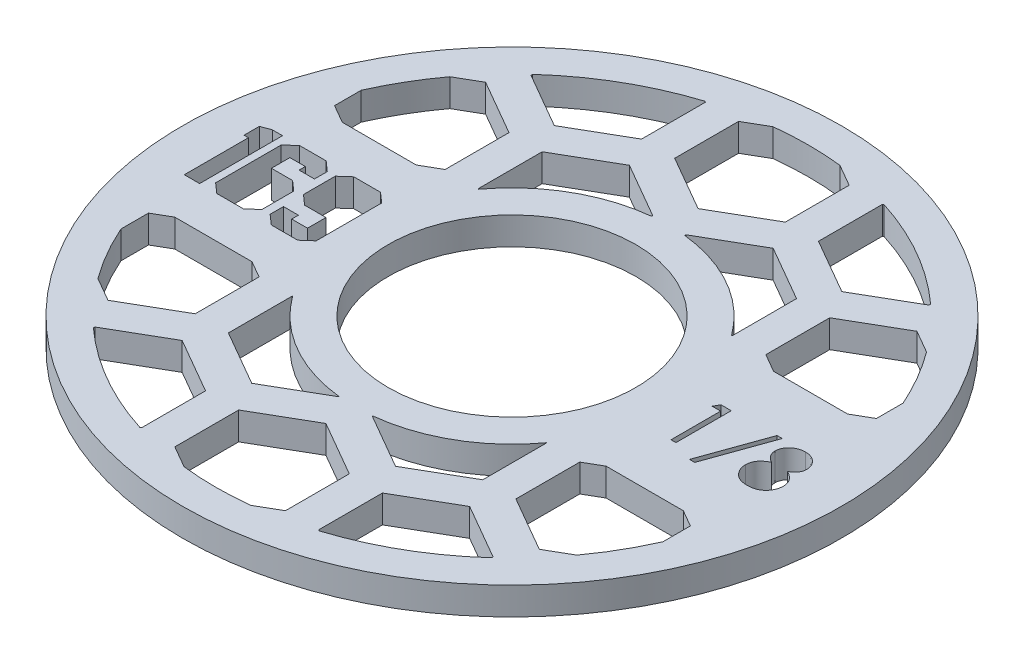
from build123d import *

# Parameters (mm, degrees)
SKETCH1_R               = 37.846
SKETCH1_R_2             = 14.224
BOSS_EXTRUDE1_DEPTH     = 3.175
CUT_EXTRUDE1_DEPTH      = 1
CUT_EXTRUDE1_DEPTH_BACK = 4.175
CUT_EXTRUDE2_DEPTH      = 1.0000001
CUT_EXTRUDE2_DEPTH_BACK = 4.1750001


with BuildPart() as part:
    # Sketch1 → Boss-Extrude1 (new body)
    with BuildSketch(Plane(origin=(0, 0, 0), x_dir=(1, 0, 0), z_dir=(0, 1, 0))):
        Circle(SKETCH1_R)
        Circle(SKETCH1_R_2, mode=Mode.SUBTRACT)
    extrude(amount=BOSS_EXTRUDE1_DEPTH)

    # Sketch2 → Cut-Extrude1 (cut, two sides)
    with BuildSketch(Plane(origin=(0, 3.175, 0), x_dir=(1, 0, 0), z_dir=(0, 1, 0))) as cut_extrude1_sk:
        Polygon((-18.723278008, -3.767243493), (-19.849678423, -4.7625), (-22.882156733, -4.7625), (-24.01035364, -3.767243493), (-24.01035364, -2.234835911), (-22.294703885, -2.234835911), (-22.294703885, -3.00373444), (-20.480247077, -3.00373444), (-20.480247077, -0.882077518), (-22.93605149, -0.882077518), (-24.058858921, 0.113178989), (-24.058858921, 3.761854017), (-22.93605149, 4.7625), (-19.862253866, 4.7625), (-18.723278008, 3.756464542), align=None)
        Polygon((-24.955308374, -3.767243493), (-26.083505281, -4.7625), (-29.139337986, -4.7625), (-30.267534892, -3.767243493), (-30.267534892, 3.761854017), (-29.151913429, 4.7625), (-26.1014702, 4.7625), (-24.973273293, 3.761854017), (-24.973273293, 2.288730668), (-26.737428329, 2.288730668), (-26.737428329, 3.00373444), (-28.508769332, 3.00373444), (-28.508769332, 0.882077518), (-26.083505281, 0.882077518), (-24.955308374, -0.105993022), align=None)
        Polygon((-31.110089589, -4.7625), (-32.868855149, -4.7625), (-32.868855149, 2.597727273), (-33.371872878, 2.597727273), (-33.371872878, 4.356492833), (-32.286791777, 4.7625), (-31.110089589, 4.7625), align=None)
        Polygon((20.831103766, 3.175), (22.005192308, 3.175), (22.005192308, -3.175), (21.435320513, -3.175), (21.435320513, 2.523717949), (20.458397436, 2.523717949), align=None)
        Polygon((27.703910256, 3.337820513), (25.047900641, -4.070512821), (24.4475, -4.070512821), (27.103509615, 3.337820513), align=None)
        with BuildLine():
            add(Edge.make_bspline(
                [(31.279601362, 0.362530048), (31.331578012, 0.335428328), (31.432949838, 0.282570923), (31.57732563, 0.197461278), (31.709269561, 0.107761242), (31.832442437, 0.017707611), (31.944680231, -0.076148385), (32.044727951, -0.174179968), (32.135056919, -0.273940183), (32.213845512, -0.377118322), (32.283145488, -0.483440271), (32.343038933, -0.593185095), (32.394233001, -0.706112286), (32.434805761, -0.823454535), (32.468228155, -0.943488152), (32.491225324, -1.067763062), (32.50359316, -1.195460366), (32.505931436, -1.281762857), (32.507115385, -1.325460737)],
                knots=[0, 0, 0, 0, 0.00017584, 0.000342947, 0.000502414, 0.000654298, 0.000800555, 0.000940883, 0.001074198, 0.001203952, 0.001329909, 0.001454575, 0.001578694, 0.001701398, 0.001826685, 0.001952179, 0.002080017, 0.002211136, 0.002211136, 0.002211136, 0.002211136], degree=3))
            add(Edge.make_bspline(
                [(32.507115385, -1.325460737), (32.505715807, -1.386598052), (32.502945519, -1.507611738), (32.478815548, -1.686221112), (32.442687715, -1.859688202), (32.389929172, -2.027974978), (32.321506305, -2.190152841), (32.237184046, -2.346360616), (32.141732288, -2.499158505), (32.065074654, -2.593173705), (32.026286058, -2.640745192)],
                knots=[0, 0, 0, 0, 0.000183332, 0.000362883, 0.000539769, 0.000714376, 0.000891093, 0.001066933, 0.001246543, 0.001430513, 0.001430513, 0.001430513, 0.001430513], degree=3))
            add(Edge.make_bspline(
                [(32.026286058, -2.640745192), (31.97578274, -2.69625104), (31.875400188, -2.806576834), (31.703436877, -2.94981616), (31.514711459, -3.070192918), (31.309954198, -3.168294784), (31.089712429, -3.244650557), (30.854033077, -3.299519125), (30.602456686, -3.330946961), (30.429545331, -3.335489913), (30.340839343, -3.337820513)],
                knots=[0, 0, 0, 0, 0.000224931, 0.000447082, 0.000669033, 0.000894901, 0.001126621, 0.001366982, 0.001619583, 0.001885684, 0.001885684, 0.001885684, 0.001885684], degree=3))
            add(Edge.make_bspline(
                [(30.340839343, -3.337820513), (30.255543624, -3.335729589), (30.089566817, -3.331660862), (29.847980382, -3.304093822), (29.62278567, -3.255783264), (29.412673299, -3.18966233), (29.218909955, -3.10364663), (29.042047758, -2.996588517), (28.879534979, -2.872797186), (28.73630352, -2.728717359), (28.609143058, -2.574398076), (28.497441019, -2.415191584), (28.404596619, -2.25108335), (28.325988889, -2.084520369), (28.265812619, -1.913168061), (28.224134466, -1.737908037), (28.197665282, -1.559046421), (28.194143509, -1.438338993), (28.192371795, -1.377614183)],
                knots=[0, 0, 0, 0, 0.000255882, 0.000497919, 0.0007282, 0.000945837, 0.001157653, 0.001362498, 0.001564768, 0.001768948, 0.001970416, 0.002164142, 0.00235158, 0.002535397, 0.002716031, 0.002895284, 0.003075177, 0.003257296, 0.003257296, 0.003257296, 0.003257296], degree=3))
            add(Edge.make_bspline(
                [(28.192371795, -1.377614183), (28.193420236, -1.333056791), (28.195492326, -1.244995659), (28.209833979, -1.114894449), (28.232890759, -0.988264319), (28.264204345, -0.864637541), (28.30664235, -0.744914147), (28.357881649, -0.628526859), (28.41762962, -0.515344279), (28.486719734, -0.404747452), (28.567096263, -0.298286052), (28.658107456, -0.194153319), (28.761572304, -0.093965074), (28.87633977, 0.003502754), (29.001098292, 0.099979164), (29.139088383, 0.190250271), (29.286651983, 0.280706865), (29.391527505, 0.334787684), (29.445326522, 0.362530048)],
                knots=[0, 0, 0, 0, 0.000133661, 0.00026416, 0.000392157, 0.000519576, 0.000646302, 0.000772746, 0.000900774, 0.001029947, 0.00116351, 0.001300524, 0.00144445, 0.001595115, 0.001752092, 0.001917202, 0.002089542, 0.002271069, 0.002271069, 0.002271069, 0.002271069], degree=3))
            add(Edge.make_bspline(
                [(29.445326522, 0.362530048), (29.371682171, 0.402688843), (29.229086094, 0.480447509), (29.040274394, 0.623316714), (28.878094263, 0.778053179), (28.747003561, 0.947924378), (28.64382109, 1.127623707), (28.573030193, 1.31602685), (28.525139429, 1.509640371), (28.520395386, 1.641913042), (28.518012821, 1.708343349)],
                knots=[0, 0, 0, 0, 0.000251342, 0.000486669, 0.000707966, 0.000921948, 0.001128163, 0.001327073, 0.001524242, 0.001723173, 0.001723173, 0.001723173, 0.001723173], degree=3))
            add(Edge.make_bspline(
                [(28.518012821, 1.708343349), (28.520979947, 1.776011777), (28.526944389, 1.912037117), (28.575174128, 2.114522512), (28.653769106, 2.31339828), (28.760668629, 2.507700502), (28.893814007, 2.690853034), (29.053555597, 2.855120179), (29.236078721, 2.999013869), (29.44047228, 3.119802068), (29.66042945, 3.218106706), (29.892505121, 3.285921845), (30.132655758, 3.330255942), (30.296118764, 3.335275444), (30.379000401, 3.337820513)],
                knots=[0, 0, 0, 0, 0.000202829, 0.000407721, 0.00062079, 0.000842814, 0.001071289, 0.001297982, 0.001528034, 0.001766476, 0.002008514, 0.00224878, 0.002490326, 0.002738767, 0.002738767, 0.002738767, 0.002738767], degree=3))
            add(Edge.make_bspline(
                [(30.379000401, 3.337820513), (30.459743036, 3.335196433), (30.618958316, 3.330022047), (30.852991426, 3.286865854), (31.076919418, 3.214785154), (31.28997008, 3.117000192), (31.488329325, 2.996555313), (31.663593515, 2.850685156), (31.818411199, 2.687142628), (31.946471457, 2.504045634), (32.051995557, 2.310490025), (32.125475763, 2.10797488), (32.172560059, 1.900875873), (32.178498877, 1.760744066), (32.181474359, 1.690534856)],
                knots=[0, 0, 0, 0, 0.000242091, 0.000477377, 0.000711103, 0.000946181, 0.001179183, 0.001405083, 0.001628266, 0.001852736, 0.002073547, 0.002287642, 0.002497223, 0.002707663, 0.002707663, 0.002707663, 0.002707663], degree=3))
            add(Edge.make_bspline(
                [(32.181474359, 1.690534856), (32.178871656, 1.621634337), (32.173760096, 1.486317634), (32.130761634, 1.289056662), (32.058347479, 1.104322391), (31.959479498, 0.930018606), (31.830618971, 0.769306461), (31.673485983, 0.620142294), (31.489333301, 0.481300762), (31.350974265, 0.402948359), (31.279601362, 0.362530048)],
                knots=[0, 0, 0, 0, 0.000206544, 0.000405641, 0.000602178, 0.000799872, 0.001004492, 0.001217712, 0.00144846, 0.001694318, 0.001694318, 0.001694318, 0.001694318], degree=3))
        make_face()
    extrude(amount=CUT_EXTRUDE1_DEPTH, mode=Mode.SUBTRACT)
    extrude(cut_extrude1_sk.sketch, amount=-CUT_EXTRUDE1_DEPTH_BACK, mode=Mode.SUBTRACT)

    # Sketch3 → Cut-Extrude2 (cut, two sides)
    with BuildSketch(Plane(origin=(0, 3.175, 0), x_dir=(1, 0, 0), z_dir=(0, 1, 0))) as cut_extrude2_sk:
        with BuildLine():
            Line((14.605, -10.631905207), (14.578021506, -10.616329166))
            ThreePointArc((14.578021506, -10.616329166), (9.017, -15.617902132), (1.905, -17.933101544))
            Line((1.905, -17.933101544), (1.905, -17.964253626))
            Line((1.905, -17.964253626), (8.255, -21.630427835))
            Line((8.255, -21.630427835), (14.605, -17.964253626))
            Line((14.605, -17.964253626), (14.605, -10.631905207))
        make_face()
        with BuildLine():
            ThreePointArc((-1.905, -17.933101544), (-9.017, -15.617902132), (-14.578021506, -10.616329166))
            Line((-14.578021506, -10.616329166), (-14.605, -10.631905207))
            Line((-14.605, -10.631905207), (-14.605, -17.964253626))
            Line((-14.605, -17.964253626), (-8.255, -21.630427835))
            Line((-8.255, -21.630427835), (-1.905, -17.964253626))
            Line((-1.905, -17.964253626), (-1.905, -17.933101544))
        make_face()
        with BuildLine():
            Line((29.197783942, -9.525), (20.332216058, -9.525))
            Line((20.332216058, -9.525), (18.415, -10.631905207))
            Line((18.415, -10.631905207), (18.415, -17.964253626))
            Line((18.415, -17.964253626), (24.765, -21.630427835))
            Line((24.765, -21.630427835), (27.504447445, -20.048807115))
            ThreePointArc((27.504447445, -20.048807115), (29.476040643, -17.018), (31.115, -13.795146647))
            Line((31.115, -13.795146647), (31.115, -10.631905207))
            Line((31.115, -10.631905207), (29.197783942, -9.525))
        make_face()
        with BuildLine():
            Line((-18.415, -10.631905207), (-20.332216058, -9.525))
            Line((-20.332216058, -9.525), (-29.197783942, -9.525))
            Line((-29.197783942, -9.525), (-31.115, -10.631905207))
            Line((-31.115, -10.631905207), (-31.115, -13.795146647))
            ThreePointArc((-31.115, -13.795146647), (-29.476040643, -17.018), (-27.504447445, -20.048807115))
            Line((-27.504447445, -20.048807115), (-24.765, -21.630427835))
            Line((-24.765, -21.630427835), (-18.415, -17.964253626))
            Line((-18.415, -17.964253626), (-18.415, -10.631905207))
        make_face()
        with BuildLine():
            ThreePointArc((1.905, 17.933101544), (8.977045814, 15.640901651), (14.523553183, 10.690723032))
            Line((14.523553183, 10.690723032), (14.605, 10.737746374))
            Line((14.605, 10.737746374), (14.605, 18.070094793))
            Line((14.605, 18.070094793), (8.255, 21.736269002))
            Line((8.255, 21.736269002), (1.905, 18.070094793))
            Line((1.905, 18.070094793), (1.905, 17.933101544))
        make_face()
        with BuildLine():
            Line((-14.605, 10.737746374), (-14.523553183, 10.690723032))
            ThreePointArc((-14.523553183, 10.690723032), (-8.977045814, 15.640901651), (-1.905, 17.933101544))
            Line((-1.905, 17.933101544), (-1.905, 18.070094793))
            Line((-1.905, 18.070094793), (-8.255, 21.736269002))
            Line((-8.255, 21.736269002), (-14.605, 18.070094793))
            Line((-14.605, 18.070094793), (-14.605, 10.737746374))
        make_face()
        with BuildLine():
            Line((18.415, 10.737746374), (20.515538337, 9.525))
            Line((20.515538337, 9.525), (29.014461663, 9.525))
            Line((29.014461663, 9.525), (31.115, 10.737746374))
            Line((31.115, 10.737746374), (31.115, 13.795146647))
            ThreePointArc((31.115, 13.795146647), (29.418907432, 17.11657622), (27.369604296, 20.232500011))
            Line((27.369604296, 20.232500011), (24.765, 21.736269002))
            Line((24.765, 21.736269002), (18.415, 18.070094793))
            Line((18.415, 18.070094793), (18.415, 10.737746374))
        make_face()
        with BuildLine():
            Line((-29.014461663, 9.525), (-20.515538337, 9.525))
            Line((-20.515538337, 9.525), (-18.415, 10.737746374))
            Line((-18.415, 10.737746374), (-18.415, 18.070094793))
            Line((-18.415, 18.070094793), (-24.765, 21.736269002))
            Line((-24.765, 21.736269002), (-27.369604296, 20.232500011))
            ThreePointArc((-27.369604296, 20.232500011), (-29.418907432, 17.11657622), (-31.115, 13.795146647))
            Line((-31.115, 13.795146647), (-31.115, 10.737746374))
            Line((-31.115, 10.737746374), (-29.014461663, 9.525))
        make_face()
        with BuildLine():
            ThreePointArc((10.290035143, -32.443250034), (16.964310844, -29.506972965), (22.86, -25.216456849))
            Line((22.86, -25.216456849), (22.86, -25.035825791))
            Line((22.86, -25.035825791), (16.51, -21.369651581))
            Line((16.51, -21.369651581), (10.16, -25.035825791))
            Line((10.16, -25.035825791), (10.16, -32.368174209))
            Line((10.16, -32.368174209), (10.290035143, -32.443250034))
        make_face()
        with BuildLine():
            Line((-22.86, -25.035825791), (-22.86, -25.216456849))
            ThreePointArc((-22.86, -25.216456849), (-16.964310844, -29.506972965), (-10.290035143, -32.443250034))
            Line((-10.290035143, -32.443250034), (-10.16, -32.368174209))
            Line((-10.16, -32.368174209), (-10.16, -25.035825791))
            Line((-10.16, -25.035825791), (-16.51, -21.369651581))
            Line((-16.51, -21.369651581), (-22.86, -25.035825791))
        make_face()
        with BuildLine():
            ThreePointArc((-3.837056844, -33.819022617), (0, -34.036), (3.837056844, -33.819022617))
            Line((3.837056844, -33.819022617), (6.35, -32.368174209))
            Line((6.35, -32.368174209), (6.35, -25.035825791))
            Line((6.35, -25.035825791), (0, -21.369651581))
            Line((0, -21.369651581), (-6.35, -25.035825791))
            Line((-6.35, -25.035825791), (-6.35, -32.368174209))
            Line((-6.35, -32.368174209), (-3.837056844, -33.819022617))
        make_face()
        with BuildLine():
            Line((22.86, 25.035825791), (22.86, 25.216456849))
            ThreePointArc((22.86, 25.216456849), (16.964310844, 29.506972965), (10.290035143, 32.443250034))
            Line((10.290035143, 32.443250034), (10.16, 32.368174209))
            Line((10.16, 32.368174209), (10.16, 25.035825791))
            Line((10.16, 25.035825791), (16.51, 21.369651581))
            Line((16.51, 21.369651581), (22.86, 25.035825791))
        make_face()
        with BuildLine():
            ThreePointArc((-10.290035143, 32.443250034), (-16.964310844, 29.506972965), (-22.86, 25.216456849))
            Line((-22.86, 25.216456849), (-22.86, 25.035825791))
            Line((-22.86, 25.035825791), (-16.51, 21.369651581))
            Line((-16.51, 21.369651581), (-10.16, 25.035825791))
            Line((-10.16, 25.035825791), (-10.16, 32.368174209))
            Line((-10.16, 32.368174209), (-10.290035143, 32.443250034))
        make_face()
        with BuildLine():
            Line((6.35, 32.368174209), (3.837056844, 33.819022617))
            ThreePointArc((3.837056844, 33.819022617), (0, 34.036), (-3.837056844, 33.819022617))
            Line((-3.837056844, 33.819022617), (-6.35, 32.368174209))
            Line((-6.35, 32.368174209), (-6.35, 25.035825791))
            Line((-6.35, 25.035825791), (0, 21.369651581))
            Line((0, 21.369651581), (6.35, 25.035825791))
            Line((6.35, 25.035825791), (6.35, 32.368174209))
        make_face()
    extrude(amount=CUT_EXTRUDE2_DEPTH, mode=Mode.SUBTRACT)
    extrude(cut_extrude2_sk.sketch, amount=-CUT_EXTRUDE2_DEPTH_BACK, mode=Mode.SUBTRACT)


solid = part.part
